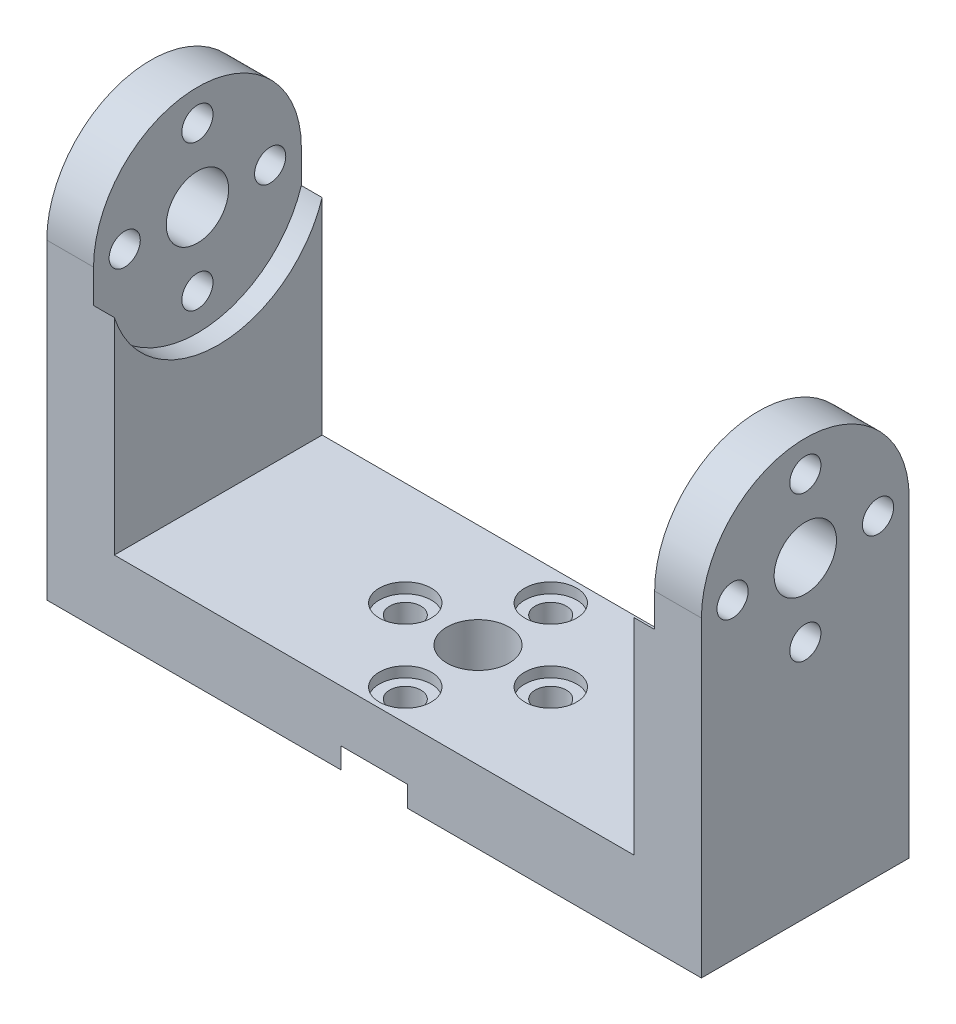
from build123d import *
from build123d.topology import SkipClean

# Parameters (mm, degrees)
CROQUIS1_W                  = 50
CROQUIS1_H                  = 20
CROQUIS1_R                  = 3
SALIENTE_EXTRUIR1_DEPTH     = 5
CROQUIS2_R                  = 10.5
CORTAR_EXTRUIR7_DEPTH       = 2
CROQUIS7_R                  = 1.5
CORTAR_EXTRUIR8_DEPTH       = 4
CROQUIS8_R                  = 2.5
CORTAR_EXTRUIR9_DEPTH       = 1
CROQUIS9_W                  = 5
CROQUIS9_H                  = 20
SALIENTE_EXTRUIR3_DEPTH     = 33
CROQUIS10_R                 = 3
CORTAR_EXTRUIR10_DEPTH      = 50
CORTAR_EXTRUIR11_DEPTH      = 42
CORTAR_EXTRUIR11_DEPTH_BACK = 2
CROQUIS11_R                 = 10.5
CORTAR_EXTRUIR12_DEPTH      = 50
CORTAR_EXTRUIR12_DEPTH_BACK = 6
CROQUIS12_R                 = 1.5
SALIENTE_EXTRUIR4_START     = 5
CROQUIS13_R                 = 1.5
CROQUIS13_R_2               = 3
SALIENTE_EXTRUIR4_DEPTH     = 5
CROQUIS14_R                 = 1.5
CROQUIS14_R_2               = 3
SALIENTE_EXTRUIR5_DEPTH     = 5
CORTAR_EXTRUIR14_DEPTH      = 45
CORTAR_EXTRUIR14_DEPTH_BACK = 5
CORTAR_EXTRUIR15_DEPTH      = 49
CORTAR_EXTRUIR15_DEPTH_BACK = 5
SALIENTE_EXTRUIR6_START     = 2
SALIENTE_EXTRUIR6_DEPTH     = 2
SALIENTE_EXTRUIR7_START     = 2
CROQUIS18_R                 = 3
CROQUIS18_R_2               = 1.5
SALIENTE_EXTRUIR7_DEPTH     = 2
SALIENTE_EXTRUIR8_START     = 1.5
CROQUIS19_R                 = 1.5
CROQUIS19_R_2               = 3
SALIENTE_EXTRUIR8_DEPTH     = 1.5
CROQUIS20_R                 = 1.5
CROQUIS20_R_2               = 3
SALIENTE_EXTRUIR9_DEPTH     = 1.5


with BuildPart() as part:
    # Croquis1 → Saliente-Extruir1 (new body)
    with BuildSketch(Plane(origin=(0, 0, 0), x_dir=(1, 0, 0), z_dir=(0, 1, 0))):
        Rectangle(CROQUIS1_W, CROQUIS1_H)
        Circle(CROQUIS1_R, mode=Mode.SUBTRACT)
    extrude(amount=SALIENTE_EXTRUIR1_DEPTH)

    # Croquis2 → Cortar-Extruir7 (cut)
    with BuildSketch(Plane.XZ):
        Circle(CROQUIS2_R)
    extrude(amount=-CORTAR_EXTRUIR7_DEPTH, mode=Mode.SUBTRACT)

    # Croquis7 → Cortar-Extruir8 (cut)
    with BuildSketch(Plane.XZ.offset(-2)):
        with Locations((0, 7)):
            Circle(CROQUIS7_R)
        with Locations((7, 0)):
            Circle(CROQUIS7_R)
        with Locations((0, -7)):
            Circle(CROQUIS7_R)
        with Locations((-7, 0)):
            Circle(CROQUIS7_R)
    extrude(amount=-CORTAR_EXTRUIR8_DEPTH, mode=Mode.SUBTRACT)

    # Croquis8 → Cortar-Extruir9 (cut)
    with BuildSketch(Plane(origin=(0, 5, 0), x_dir=(1, 0, 0), z_dir=(0, 1, 0))):
        with Locations((0, 7)):
            Circle(CROQUIS8_R)
        with Locations((7, 0)):
            Circle(CROQUIS8_R)
        with Locations((0, -7)):
            Circle(CROQUIS8_R)
        with Locations((-7, 0)):
            Circle(CROQUIS8_R)
    extrude(amount=-CORTAR_EXTRUIR9_DEPTH, mode=Mode.SUBTRACT)

    # Croquis9 → Saliente-Extruir3 (add)
    with BuildSketch(Plane(origin=(0, 5, 0), x_dir=(1, 0, 0), z_dir=(0, 1, 0))):
        with Locations((22.5, 0)):
            Rectangle(CROQUIS9_W, CROQUIS9_H)
        with Locations((-22.5, 0)):
            Rectangle(CROQUIS9_W, CROQUIS9_H)
    extrude(amount=SALIENTE_EXTRUIR3_DEPTH)

    # Croquis10 → Cortar-Extruir10 (cut)
    with BuildSketch(Plane(origin=(25, 0, 0), x_dir=(0, 0, -1), z_dir=(1, 0, 0))):
        with Locations((0, 28)):
            Circle(CROQUIS10_R)
        with BuildLine():
            Line((10, 28), (21.898985217, 31.221805306))
            Line((21.898985217, 31.221805306), (12.889165909, 40.913504361))
            Line((12.889165909, 40.913504361), (-22.207421629, 40.012243034))
            Line((-22.207421629, 40.012243034), (-10, 28))
            ThreePointArc((-10, 28), (0, 38), (10, 28))
        make_face()
    extrude(amount=-CORTAR_EXTRUIR10_DEPTH, mode=Mode.SUBTRACT)

    # Croquis11 → Cortar-Extruir11 (cut, two sides: drawn at the far end of the back side and taken through both)
    with BuildSketch(Plane(origin=(-20, 0, 0), x_dir=(0, 0, -1), z_dir=(1, 0, 0)).offset(-CORTAR_EXTRUIR11_DEPTH_BACK)):
        with Locations((0, 28)):
            Circle(CROQUIS11_R)
    extrude(amount=CORTAR_EXTRUIR11_DEPTH + CORTAR_EXTRUIR11_DEPTH_BACK, mode=Mode.SUBTRACT)

    # Croquis12 → Cortar-Extruir12 (cut, two sides: drawn at the far end of the back side and taken through both)
    with BuildSketch(Plane(origin=(-22, 0, 0), x_dir=(0, 0, -1), z_dir=(1, 0, 0)).offset(-CORTAR_EXTRUIR12_DEPTH_BACK)):
        with Locations((0, 35)):
            Circle(CROQUIS12_R)
        with Locations((7, 28)):
            Circle(CROQUIS12_R)
        with Locations((0, 21)):
            Circle(CROQUIS12_R)
        with Locations((-7, 28)):
            Circle(CROQUIS12_R)
    extrude(amount=CORTAR_EXTRUIR12_DEPTH + CORTAR_EXTRUIR12_DEPTH_BACK, mode=Mode.SUBTRACT)

    # Croquis13 → Saliente-Extruir4 (add)
    with BuildSketch(Plane(origin=(25, 0, 0), x_dir=(0, 0, -1), z_dir=(1, 0, 0)).offset(SALIENTE_EXTRUIR4_START)):
        with BuildLine():
            Line((10, 0), (10, 28))
            ThreePointArc((10, 28), (0, 38), (-10, 28))
            Line((-10, 28), (-10, 0))
            Line((-10, 0), (10, 0))
        make_face()
        with Locations((-7, 28)):
            Circle(CROQUIS13_R, mode=Mode.SUBTRACT)
        with Locations((0, 28)):
            Circle(CROQUIS13_R_2, mode=Mode.SUBTRACT)
        with Locations((7, 28)):
            Circle(CROQUIS13_R, mode=Mode.SUBTRACT)
        with Locations((0, 35)):
            Circle(CROQUIS13_R, mode=Mode.SUBTRACT)
        with Locations((0, 21)):
            Circle(CROQUIS13_R, mode=Mode.SUBTRACT)
    extrude(amount=-SALIENTE_EXTRUIR4_DEPTH)

    # Croquis14 → Saliente-Extruir5 (add)
    with BuildSketch(Plane.ZY.offset(25)):
        with BuildLine():
            Line((10, 0), (10, 28))
            ThreePointArc((10, 28), (0, 38), (-10, 28))
            Line((-10, 28), (-10, 0))
            Line((-10, 0), (10, 0))
        make_face()
        with Locations((0, 21)):
            Circle(CROQUIS14_R, mode=Mode.SUBTRACT)
        with Locations((0, 28)):
            Circle(CROQUIS14_R_2, mode=Mode.SUBTRACT)
        with Locations((-7, 28)):
            Circle(CROQUIS14_R, mode=Mode.SUBTRACT)
        with Locations((0, 35)):
            Circle(CROQUIS14_R, mode=Mode.SUBTRACT)
        with Locations((7, 28)):
            Circle(CROQUIS14_R, mode=Mode.SUBTRACT)
    extrude(amount=SALIENTE_EXTRUIR5_DEPTH)

    # Croquis15 → Cortar-Extruir14 (cut, two sides: drawn at the far end of the back side and taken through both)
    with SkipClean():  # the faces are left unmerged after this step: merging them gives an invalid solid
        with BuildSketch(Plane(origin=(-20, 0, 0), x_dir=(0, 0, -1), z_dir=(1, 0, 0)).offset(-CORTAR_EXTRUIR14_DEPTH_BACK)):
            with BuildLine():
                Line((-10, 24.798437881), (-10, 5))
                Line((-10, 5), (10, 5))
                Line((10, 5), (10, 24.798437881))
                ThreePointArc((10, 24.798437881), (0, 17.5), (-10, 24.798437881))
            make_face()
        extrude(amount=CORTAR_EXTRUIR14_DEPTH + CORTAR_EXTRUIR14_DEPTH_BACK, mode=Mode.SUBTRACT)

    # Croquis16 → Cortar-Extruir15 (cut, two sides: drawn at the far end of the back side and taken through both)
    with BuildSketch(Plane(origin=(-22, 0, 0), x_dir=(0, 0, -1), z_dir=(1, 0, 0)).offset(-CORTAR_EXTRUIR15_DEPTH_BACK)):
        with BuildLine():
            Line((-10, 28), (-10, 24.798437881))
            ThreePointArc((-10, 24.798437881), (0, 17.5), (10, 24.798437881))
            Line((10, 24.798437881), (10, 28))
            ThreePointArc((10, 28), (0, 38), (-10, 28))
        make_face()
    extrude(amount=CORTAR_EXTRUIR15_DEPTH + CORTAR_EXTRUIR15_DEPTH_BACK, mode=Mode.SUBTRACT)

    # Croquis17 → Saliente-Extruir6 (add)
    with SkipClean():  # the faces are left unmerged after this step: merging them gives an invalid solid
        with BuildSketch(Plane.XZ.offset(SALIENTE_EXTRUIR6_START)):
            with BuildLine():
                Line((30, 10), (3.201562119, 10))
                ThreePointArc((3.201562119, 10), (10.5, 0), (3.201562119, -10))
                Line((3.201562119, -10), (30, -10))
                Line((30, -10), (30, 10))
            make_face()
            with BuildLine():
                Line((-30, -10), (-3.201562119, -10))
                ThreePointArc((-3.201562119, -10), (-10.5, 0), (-3.201562119, 10))
                Line((-3.201562119, 10), (-30, 10))
                Line((-30, 10), (-30, -10))
            make_face()
        extrude(amount=-SALIENTE_EXTRUIR6_DEPTH)

    # Croquis18 → Saliente-Extruir7 (add)
    with BuildSketch(Plane.XZ.offset(-2).offset(SALIENTE_EXTRUIR7_START)):
        with BuildLine():
            Line((3.201562119, 10), (-3.201562119, 10))
            ThreePointArc((-3.201562119, 10), (-10.5, 0), (-3.201562119, -10))
            Line((-3.201562119, -10), (3.201562119, -10))
            ThreePointArc((3.201562119, -10), (10.5, 0), (3.201562119, 10))
        make_face()
        Circle(CROQUIS18_R, mode=Mode.SUBTRACT)
        with Locations((7, 0)):
            Circle(CROQUIS18_R_2, mode=Mode.SUBTRACT)
        with Locations((0, 7)):
            Circle(CROQUIS18_R_2, mode=Mode.SUBTRACT)
        with Locations((-7, 0)):
            Circle(CROQUIS18_R_2, mode=Mode.SUBTRACT)
        with Locations((0, -7)):
            Circle(CROQUIS18_R_2, mode=Mode.SUBTRACT)
    extrude(amount=-SALIENTE_EXTRUIR7_DEPTH)

    # Croquis19 → Saliente-Extruir8 (add)
    with BuildSketch(Plane(origin=(30, 0, 0), x_dir=(0, 0, -1), z_dir=(1, 0, 0)).offset(SALIENTE_EXTRUIR8_START)):
        with BuildLine():
            Line((-10, 28), (-10, -2))
            Line((-10, -2), (10, -2))
            Line((10, -2), (10, 28))
            ThreePointArc((10, 28), (0, 38), (-10, 28))
        make_face()
        with Locations((7, 28)):
            Circle(CROQUIS19_R, mode=Mode.SUBTRACT)
        with Locations((0, 21)):
            Circle(CROQUIS19_R, mode=Mode.SUBTRACT)
        with Locations((0, 28)):
            Circle(CROQUIS19_R_2, mode=Mode.SUBTRACT)
        with Locations((-7, 28)):
            Circle(CROQUIS19_R, mode=Mode.SUBTRACT)
        with Locations((0, 35)):
            Circle(CROQUIS19_R, mode=Mode.SUBTRACT)
    extrude(amount=-SALIENTE_EXTRUIR8_DEPTH)

    # Croquis20 → Saliente-Extruir9 (add)
    with BuildSketch(Plane.ZY.offset(30)):
        with BuildLine():
            Line((-10, 28), (-10, -2))
            Line((-10, -2), (10, -2))
            Line((10, -2), (10, 28))
            ThreePointArc((10, 28), (0, 38), (-10, 28))
        make_face()
        with Locations((0, 21)):
            Circle(CROQUIS20_R, mode=Mode.SUBTRACT)
        with Locations((0, 28)):
            Circle(CROQUIS20_R_2, mode=Mode.SUBTRACT)
        with Locations((7, 28)):
            Circle(CROQUIS20_R, mode=Mode.SUBTRACT)
        with Locations((0, 35)):
            Circle(CROQUIS20_R, mode=Mode.SUBTRACT)
        with Locations((-7, 28)):
            Circle(CROQUIS20_R, mode=Mode.SUBTRACT)
    extrude(amount=SALIENTE_EXTRUIR9_DEPTH)


solid = part.part
